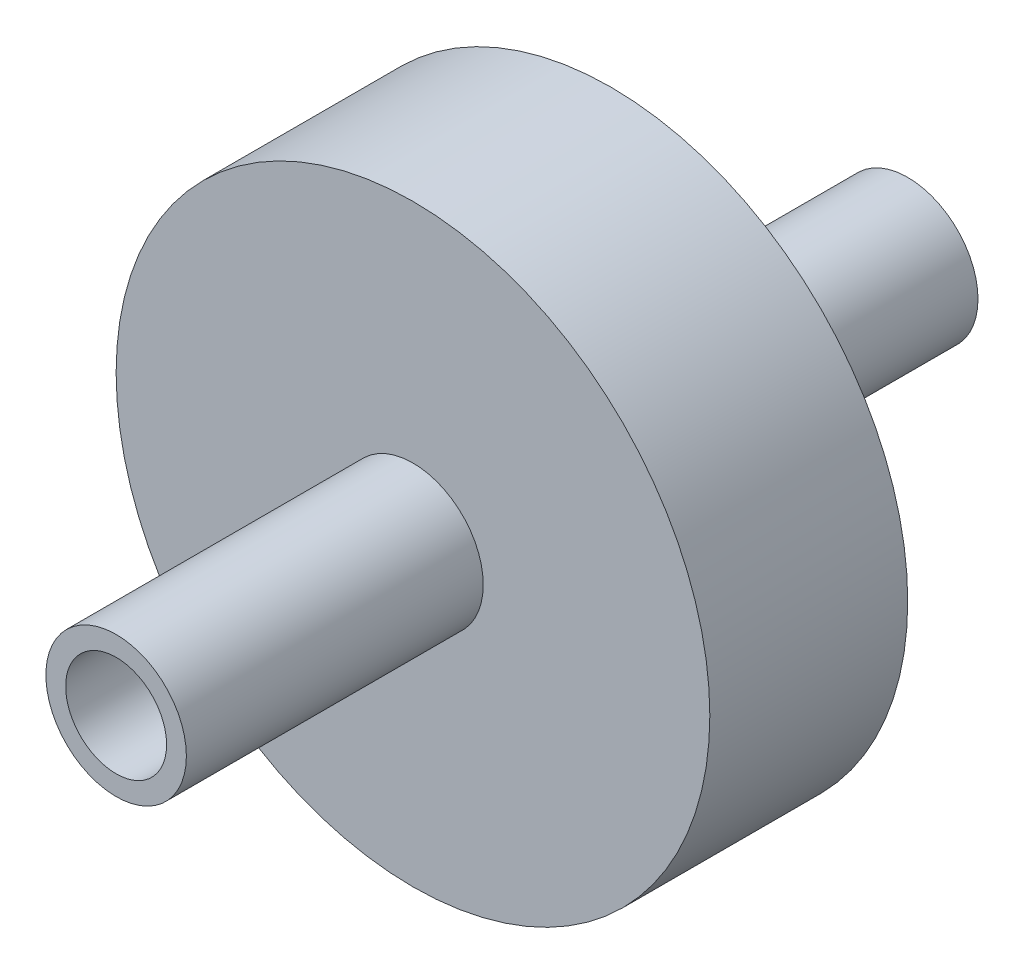
from build123d import *

# Parameters (mm, degrees)
SKETCH3_R                = 15
BOSS_EXTRUDE1_DEPTH      = 10
SKETCH4_R                = 3.55
SKETCH4_R_2              = 2.55
BOSS_EXTRUDE2_DEPTH      = 15
BOSS_EXTRUDE2_DEPTH_BACK = 25
SKETCH9_R                = 2.55
CUT_EXTRUDE1_DEPTH       = 26


with BuildPart() as part:
    # Sketch3 → Boss-Extrude1 (new body)
    with BuildSketch(Plane.XY):
        Circle(SKETCH3_R)
    extrude(amount=BOSS_EXTRUDE1_DEPTH)

    # Sketch4 → Boss-Extrude2 (add, two sides)
    with BuildSketch(Plane.XY.offset(10)) as boss_extrude2_sk:
        Circle(SKETCH4_R)
        Circle(SKETCH4_R_2, mode=Mode.SUBTRACT)
    extrude(amount=BOSS_EXTRUDE2_DEPTH)
    extrude(boss_extrude2_sk.sketch, amount=-BOSS_EXTRUDE2_DEPTH_BACK)

    # Sketch9 → Cut-Extrude1 (cut, through all)
    with BuildSketch(Plane.XY.offset(10)):
        Circle(SKETCH9_R)
    extrude(amount=-CUT_EXTRUDE1_DEPTH, mode=Mode.SUBTRACT)


solid = part.part
